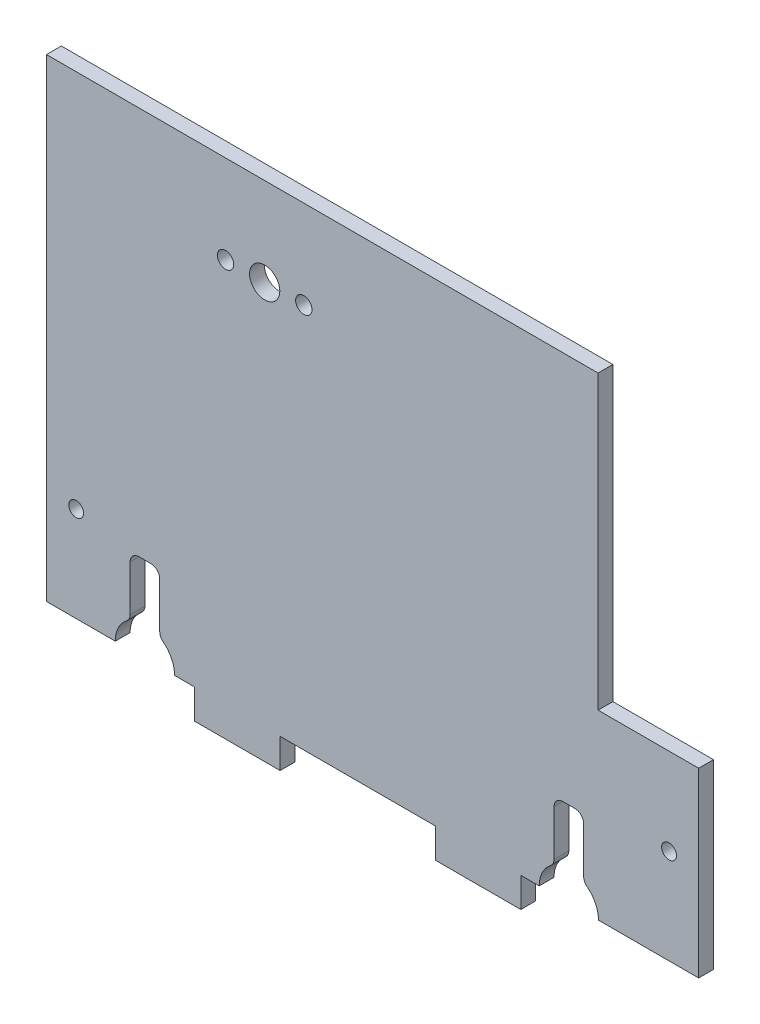
from build123d import *

# Parameters (mm, degrees)
BOSS_EXTRUDE1_DEPTH = 3.175
SKETCH2_R           = 1.5875
CUT_EXTRUDE1_DEPTH  = 3.175
BOSS_EXTRUDE2_DEPTH = 3.175
CUT_EXTRUDE2_DEPTH  = 3.175
SKETCH5_W           = 1.5875
SKETCH5_H           = 12.7
CUT_EXTRUDE3_DEPTH  = 10.16
LPATTERN1_COUNT     = 2
LPATTERN1_PITCH     = 25.4
SKETCH8_W           = 38.1
SKETCH8_H           = 46.355
CUT_EXTRUDE6_DEPTH  = 12.7
SKETCH10_R          = 1.5875
CUT_EXTRUDE7_DEPTH  = 7.62
CUT_EXTRUDE8_DEPTH  = 12.7
FILLET1_R           = 25.4
SKETCH13_W          = 25.4
SKETCH13_H          = 177.8
BOSS_EXTRUDE3_DEPTH = 3.175
LPATTERN2_COUNT     = 2
LPATTERN2_PITCH     = 76.2
SKETCH14_W          = 19.05
SKETCH14_H          = 6.35
BOSS_EXTRUDE4_DEPTH = 3.175
FILLET2_R           = 1.905
CUT_EXTRUDE9_DEPTH  = 392.916423648
SKETCH16_R          = 3.2385
CUT_EXTRUDE10_DEPTH = 205.735785414
SKETCH17_R          = 1.75
CUT_EXTRUDE11_DEPTH = 205.735785414
SKETCH18_W          = 33.274
SKETCH18_H          = 6.35
CUT_EXTRUDE12_DEPTH = 205.735785414


with BuildPart() as part:
    # Sketch1 → Boss-Extrude1 (new body)
    with BuildSketch(Plane.XY):
        Polygon((0, 0), (-177.8, 0), (-177.8, 349.25), (-25.4, 349.25), align=None)
    extrude(amount=BOSS_EXTRUDE1_DEPTH)

    # Sketch2 → Cut-Extrude1 (cut)
    with BuildSketch(Plane.XY.offset(3.175)):
        with Locations((-127, 133.35)):
            Circle(SKETCH2_R)
        with Locations((-127, 306.07)):
            Circle(SKETCH2_R)
    extrude(amount=-CUT_EXTRUDE1_DEPTH, mode=Mode.SUBTRACT)

    # Sketch3 → Boss-Extrude2 (add)
    with BuildSketch(Plane.XY.offset(3.175)):
        Polygon((-63.5, 88.9), (63.5, 111.29352655), (63.5, 187.49352655), (-63.5, 187.49352655), align=None)
    extrude(amount=-BOSS_EXTRUDE2_DEPTH)

    # Sketch4 → Cut-Extrude2 (cut)
    with BuildSketch(Plane.XY.offset(3.175)):
        Polygon((-44.45, 110.49), (-31.942941537, 112.695331856), (-32.494274501, 115.822096472), (-45.001332964, 113.616764616), align=None)
        Polygon((-6.92882461, 117.105995569), (5.578233853, 119.311327425), (5.026900889, 122.438092041), (-7.480157574, 120.232760185), align=None)
    cut_extrude2 = extrude(amount=-CUT_EXTRUDE2_DEPTH, mode=Mode.SUBTRACT)

    # Sketch5 → Cut-Extrude3 (cut)
    with BuildSketch(Plane.XY.offset(3.175)):
        with Locations((-126.20625, 209.55)):
            Rectangle(SKETCH5_W, SKETCH5_H)
        with Locations((-127.79375, 209.55)):
            Rectangle(SKETCH5_W, SKETCH5_H)
    cut_extrude3 = extrude(amount=-CUT_EXTRUDE3_DEPTH, mode=Mode.SUBTRACT)

    # LPattern1: Cut-Extrude3 ×2
    with Locations(*[(0, i * LPATTERN1_PITCH, 0) for i in range(1, LPATTERN1_COUNT)]):
        add(cut_extrude3, mode=Mode.SUBTRACT)

    # Sketch8 → Cut-Extrude6 (cut)
    with BuildSketch(Plane.XY.offset(3.175)):
        with Locations((-19.05, 23.1775)):
            Rectangle(SKETCH8_W, SKETCH8_H)
    extrude(amount=-CUT_EXTRUDE6_DEPTH, mode=Mode.SUBTRACT)

    # Sketch10 → Cut-Extrude7 (cut)
    with BuildSketch(Plane(origin=(0, 0, 0), x_dir=(-1, 0, 0), z_dir=(0, 0, -1))):
        with Locations((171.45, 20.32)):
            Circle(SKETCH10_R)
        with Locations((44.45, 20.32)):
            Circle(SKETCH10_R)
    extrude(amount=-CUT_EXTRUDE7_DEPTH, mode=Mode.SUBTRACT)

    # Sketch11 → Cut-Extrude8 (cut)
    with BuildSketch(Plane(origin=(0, 0, 0), x_dir=(-1, 0, 0), z_dir=(0, 0, -1))):
        with BuildLine():
            Line((62.738, 18.199261314), (62.738, 5.499261314))
            ThreePointArc((62.738, 5.499261314), (65.913, 6.35), (69.088, 5.499261314))
            Line((69.088, 5.499261314), (69.088, 18.199261314))
            Line((69.088, 18.199261314), (62.738, 18.199261314))
        make_face()
        with BuildLine():
            Line((69.088, 5.499261314), (62.738, 5.499261314))
            ThreePointArc((62.738, 5.499261314), (60.413738686, 3.175), (59.563, 0))
            Line((59.563, 0), (72.263, 0))
            ThreePointArc((72.263, 0), (71.412261314, 3.175), (69.088, 5.499261314))
        make_face()
        with BuildLine():
            ThreePointArc((153.543, 5.499261314), (151.218738686, 3.175), (150.368, 0))
            Line((150.368, 0), (163.068, 0))
            ThreePointArc((163.068, 0), (162.217261314, 3.175), (159.893, 5.499261314))
            Line((159.893, 5.499261314), (153.543, 5.499261314))
        make_face()
        with BuildLine():
            Line((153.543, 18.199261314), (153.543, 5.499261314))
            ThreePointArc((153.543, 5.499261314), (156.718, 6.35), (159.893, 5.499261314))
            Line((159.893, 5.499261314), (159.893, 18.199261314))
            Line((159.893, 18.199261314), (153.543, 18.199261314))
        make_face()
        with BuildLine():
            ThreePointArc((159.893, 5.499261314), (156.718, 6.35), (153.543, 5.499261314))
            Line((153.543, 5.499261314), (159.893, 5.499261314))
        make_face()
    extrude(amount=-CUT_EXTRUDE8_DEPTH, mode=Mode.SUBTRACT)


with BuildPart() as cut_extrude8_kept_piece:
    # of the separate pieces the step leaves, the one the design keeps (cut_extrude8_pieces_kept)
    add(part.part.solids().sort_by_distance((-38.1, 0, 0))[0])

    # Fillet1
    fillet1_edges = [cut_extrude8_kept_piece.edges().sort_by_distance(p)[0] for p in [
        (-38.1, 46.355, 1.5875),
    ]]
    fillet(fillet1_edges, radius=FILLET1_R)

    # Sketch13 → Boss-Extrude3 (add)
    with BuildSketch(Plane(origin=(0, 0, 0), x_dir=(-1, 0, 0), z_dir=(0, 0, -1))):
        with Locations((12.7, 260.35)):
            Rectangle(SKETCH13_W, SKETCH13_H)
    extrude(amount=-BOSS_EXTRUDE3_DEPTH)

    # LPattern2: Cut-Extrude2 ×2
    with Locations(*[Vector(0.9848077530122078, 0.17364817766693205, 0) * (i * LPATTERN2_PITCH) for i in range(1, LPATTERN2_COUNT)]):
        add(cut_extrude2, mode=Mode.SUBTRACT)

    # Sketch14 → Boss-Extrude4 (add)
    with BuildSketch(Plane(origin=(0, 0, 0), x_dir=(-1, 0, 0), z_dir=(0, 0, -1))):
        with Locations((85.725, -3.175)):
            Rectangle(SKETCH14_W, SKETCH14_H)
        with Locations((136.525, -3.175)):
            Rectangle(SKETCH14_W, SKETCH14_H)
    extrude(amount=-BOSS_EXTRUDE4_DEPTH)

    # Fillet2
    fillet2_edges = [cut_extrude8_kept_piece.edges().sort_by_distance(p)[0] for p in [
        (-153.543, 5.499261314, 1.5875),
        (-153.543, 18.199261314, 1.5875),
        (-159.893, 18.199261314, 1.5875),
        (-159.893, 5.499261314, 1.5875),
        (-62.738, 5.499261314, 1.5875),
        (-62.738, 18.199261314, 1.5875),
        (-69.088, 18.199261314, 1.5875),
        (-69.088, 5.499261314, 1.5875),
    ]]
    fillet(fillet2_edges, radius=FILLET2_R)

    # Sketch15 → Cut-Extrude9 (cut, through all)
    with BuildSketch(Plane(origin=(0, 0, 0), x_dir=(-1, 0, 0), z_dir=(0, 0, -1))):
        Polygon((38.1, 20.955), (38.1, 38.915512242), (59.646092876, 38.915512242), (59.646092876, 87.95072106), (59.646092876, 101.458470342), (177.8, 101.458470342), (320.979610432, 349.25), (0, 416.848504921), (-115.466676424, 312.716348385), (-102.18599125, 94.704595701), align=None)
    extrude(amount=-CUT_EXTRUDE9_DEPTH, mode=Mode.SUBTRACT)

    # Sketch16 → Cut-Extrude10 (cut, through all)
    with BuildSketch(Plane.XY.offset(3.175)):
        with Locations((-131.064, 82.55)):
            Circle(SKETCH16_R)
    extrude(amount=-CUT_EXTRUDE10_DEPTH, mode=Mode.SUBTRACT)

    # Sketch17 → Cut-Extrude11 (cut, through all)
    with BuildSketch(Plane.XY.offset(3.175)):
        with Locations((-122.682, 82.55)):
            Circle(SKETCH17_R)
        with Locations(Location((-139.446, 82.55, 0), (0, 0, 180))):
            Circle(SKETCH17_R)
    extrude(amount=-CUT_EXTRUDE11_DEPTH, mode=Mode.SUBTRACT)

    # Sketch18 → Cut-Extrude12 (cut, through all)
    with BuildSketch(Plane(origin=(0, 0, 0), x_dir=(-1, 0, 0), z_dir=(0, 0, -1))):
        with Locations((111.125, -3.175)):
            Rectangle(SKETCH18_W, SKETCH18_H)
    extrude(amount=-CUT_EXTRUDE12_DEPTH, mode=Mode.SUBTRACT)


solid = cut_extrude8_kept_piece.part
